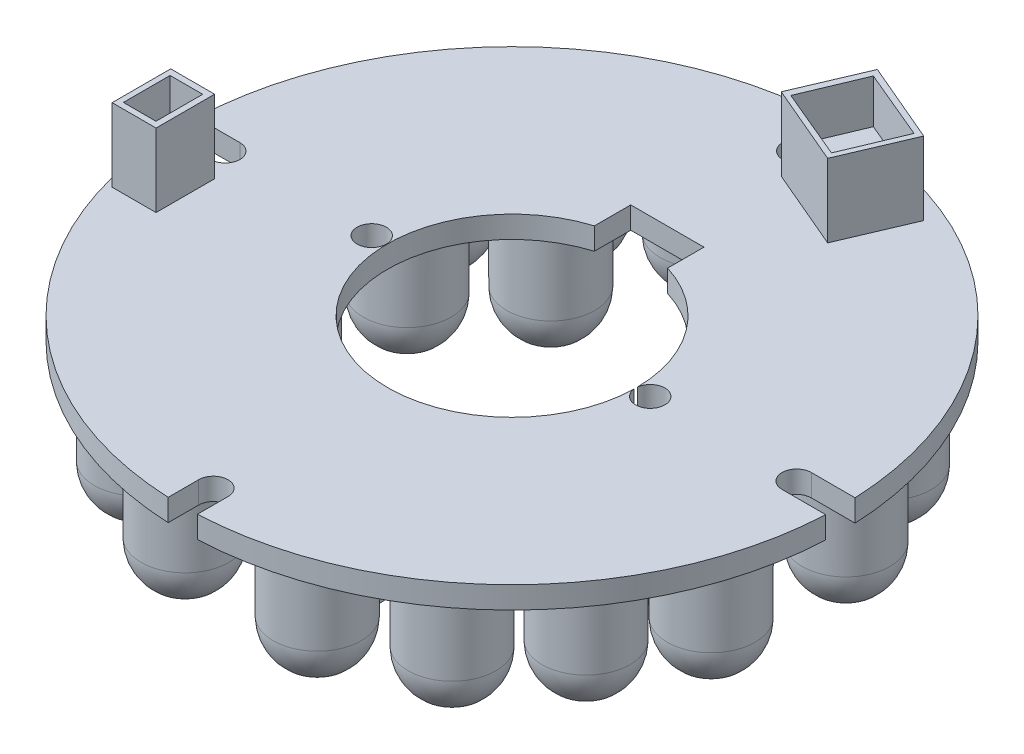
from build123d import *

# Parameters (mm, degrees)
SKETCH1_R           = 22.5
BOSS_EXTRUDE1_DEPTH = 1.5
SKETCH1_4_R         = 1
CUT_EXTRUDE1_DEPTH  = 10
SKETCH3_W           = 3
SKETCH3_H           = 4
BOSS_EXTRUDE2_DEPTH = 5
SKETCH4_R           = 3
BOSS_EXTRUDE3_DEPTH = 8
FILLET1_R           = 3
SKETCH5_R           = 2.437634963
CUT_EXTRUDE2_DEPTH  = 1
SKETCH6_W           = 2.226470075
SKETCH6_H           = 3.189267945
CUT_EXTRUDE3_DEPTH  = 3


with BuildPart() as part:
    # Sketch1 → Boss-Extrude1 (new body)
    with BuildSketch(Plane(origin=(0, 0, 0), x_dir=(1, 0, 0), z_dir=(0, 1, 0))):
        Circle(SKETCH1_R)
    extrude(amount=BOSS_EXTRUDE1_DEPTH)

    # Sketch1_4 → Cut-Extrude1 (cut)
    with BuildSketch(Plane(origin=(0, 0, 0), x_dir=(1, 0, 0), z_dir=(0, 1, 0))):
        with BuildLine():
            Line((-22.475306545, -1.053848038), (-19.525005447, -1.053848038))
            ThreePointArc((-19.525005447, -1.053848038), (-18.525005447, -0.053848038), (-19.525005447, 0.946151962))
            Line((-19.525005447, 0.946151962), (-22.480097786, 0.946151962))
            ThreePointArc((-22.480097786, 0.946151962), (-22.499935437, -0.0539013), (-22.475306545, -1.053848038))
        make_face()
        with BuildLine():
            Line((-1, -20.392849405), (-1, -22.477766793))
            ThreePointArc((-1, -22.477766793), (0, -22.5), (1, -22.477766793))
            Line((1, -22.477766793), (1, -20.392849405))
            ThreePointArc((1, -20.392849405), (0, -19.392849405), (-1, -20.392849405))
        make_face()
        with BuildLine():
            ThreePointArc((1, 22.477766793), (0, 22.5), (-1, 22.477766793))
            Line((-1, 22.477766793), (-1, 19.477766793))
            ThreePointArc((-1, 19.477766793), (0, 18.477766793), (1, 19.477766793))
            Line((1, 19.477766793), (1, 22.477766793))
        make_face()
        with BuildLine():
            Line((19.493539425, -1.053848038), (22.475306545, -1.053848038))
            ThreePointArc((22.475306545, -1.053848038), (22.499935437, -0.0539013), (22.480097786, 0.946151962))
            Line((22.480097786, 0.946151962), (19.493539425, 0.946151962))
            ThreePointArc((19.493539425, 0.946151962), (18.493539425, -0.053848038), (19.493539425, -1.053848038))
        make_face()
        with BuildLine():
            Line((2.5, 10.607150595), (-2.5, 10.607150595))
            Line((-2.5, 10.607150595), (-2.5, 8.124038405))
            ThreePointArc((-2.5, 8.124038405), (-5.111612704, -6.791274958), (8.4985991, -0.154315694))
            ThreePointArc((8.4985991, -0.154315694), (10.493523339, -0.059520018), (8.4998028, 0.057899538))
            ThreePointArc((8.4998028, 0.057899538), (6.820158683, 5.0730105), (2.5, 8.124038405))
            Line((2.5, 8.124038405), (2.5, 10.607150595))
        make_face()
        with Locations((-9.525005447, -0.053848038)):
            Circle(SKETCH1_4_R)
    extrude(amount=CUT_EXTRUDE1_DEPTH, mode=Mode.SUBTRACT)

    # Sketch3 → Boss-Extrude2 (add)
    with BuildSketch(Plane(origin=(0, 1.5, 0), x_dir=(1, 0, 0), z_dir=(0, 1, 0))):
        Polygon((2.912812777, 22.035279399), (0.952320574, 17.435663076), (6.471860162, 15.083072432), (8.432352365, 19.682688755), align=None)
        with Locations((-19.750427717, -4.053848038)):
            Rectangle(SKETCH3_W, SKETCH3_H)
    extrude(amount=BOSS_EXTRUDE2_DEPTH)

    # Sketch4 → Boss-Extrude3 (add)
    with BuildSketch(Plane.XZ):
        with Locations((0, 12.095148247)):
            Circle(SKETCH4_R)
        with Locations((-4.573289884, 17.751585735)):
            Circle(SKETCH4_R)
        with Locations((4.573289884, 17.871935469)):
            Circle(SKETCH4_R)
        with Locations((10.951825776, 15.043716725)):
            Circle(SKETCH4_R)
        with Locations((6.79975996, 9.748328438)):
            Circle(SKETCH4_R)
        with Locations((18.112634937, 4.513115017)):
            Circle(SKETCH4_R)
        with Locations((15.164066458, 10.109377639)):
            Circle(SKETCH4_R)
        with Locations((11.192525243, 4.813989352)):
            Circle(SKETCH4_R)
        with Locations((18.23298467, -4.573289884)):
            Circle(SKETCH4_R)
        with Locations((11.192525243, -4.633464751)):
            Circle(SKETCH4_R)
        with Locations((15.103891592, -10.530601707)):
            Circle(SKETCH4_R)
        with Locations((6.679410226, -9.989027905)):
            Circle(SKETCH4_R)
        with Locations((9.086404902, -16.367563796)):
            Circle(SKETCH4_R)
        with Locations((2.166295208, -14.74284239)):
            Circle(SKETCH4_R)
        with Locations((-4.874164219, -17.992285203)):
            Circle(SKETCH4_R)
        with Locations((-10.951825776, -14.923366991)):
            Circle(SKETCH4_R)
        with Locations((-6.98028456, -9.627978704)):
            Circle(SKETCH4_R)
        with Locations((-11.493399578, -4.332590417)):
            Circle(SKETCH4_R)
        with Locations((-18.172809803, -4.332590417)):
            Circle(SKETCH4_R)
        with Locations((-15.164066458, -10.049202772)):
            Circle(SKETCH4_R)
        with Locations((-14.983541858, 1.022972737)):
            Circle(SKETCH4_R)
        with Locations((-10.350077107, 5.536087755)):
            Circle(SKETCH4_R)
        with Locations((-16.909137599, 7.521858362)):
            Circle(SKETCH4_R)
        with Locations((-5.957311823, 10.049202772)):
            Circle(SKETCH4_R)
        with Locations((-10.711126308, 14.803017257)):
            Circle(SKETCH4_R)
    extrude(amount=BOSS_EXTRUDE3_DEPTH)

    # Fillet1
    fillet1_edges = [part.edges().sort_by_distance(p)[0] for p in [
        (-0.833704792, -8, -14.74284239),
        (3.679410226, -8, -9.989027905),
        (6.086404902, -8, -16.367563796),
        (12.103891592, -8, -10.530601707),
        (8.192525243, -8, -4.633464751),
        (15.23298467, -8, -4.573289884),
        (15.112634937, -8, 4.513115017),
        (8.192525243, -8, 4.813989352),
        (12.164066458, -8, 10.109377639),
        (7.951825776, -8, 15.043716725),
        (3.79975996, -8, 9.748328438),
        (1.573289884, -8, 17.871935469),
        (-7.573289884, -8, 17.751585735),
        (-13.711126308, -8, 14.803017257),
        (-8.957311823, -8, 10.049202772),
        (-19.909137599, -8, 7.521858362),
        (-13.350077107, -8, 5.536087755),
        (-17.983541858, -8, 1.022972737),
        (-21.172809803, -8, -4.332590417),
        (-14.493399578, -8, -4.332590417),
        (-9.98028456, -8, -9.627978704),
        (-7.874164219, -8, -17.992285203),
        (-13.951825776, -8, -14.923366991),
        (-18.164066458, -8, -10.049202772),
    ]]
    fillet(fillet1_edges, radius=FILLET1_R)

    # Sketch5 → Cut-Extrude2 (cut)
    with BuildSketch(Plane.XZ.offset(8)):
        with Locations((0, 12.064702743)):
            Circle(SKETCH5_R)
    extrude(amount=-CUT_EXTRUDE2_DEPTH, mode=Mode.SUBTRACT)

    # Sketch6 → Cut-Extrude3 (cut)
    with BuildSketch(Plane(origin=(0, 6.5, 0), x_dir=(1, 0, 0), z_dir=(0, 1, 0))):
        Polygon((1.494724423, 17.542466767), (3.161284436, 21.513843818), (7.946639755, 19.50570364), (6.280079742, 15.534326588), align=None)
        with Locations((-19.767443777, -4.061803516)):
            Rectangle(SKETCH6_W, SKETCH6_H)
    extrude(amount=-CUT_EXTRUDE3_DEPTH, mode=Mode.SUBTRACT)


solid = part.part
